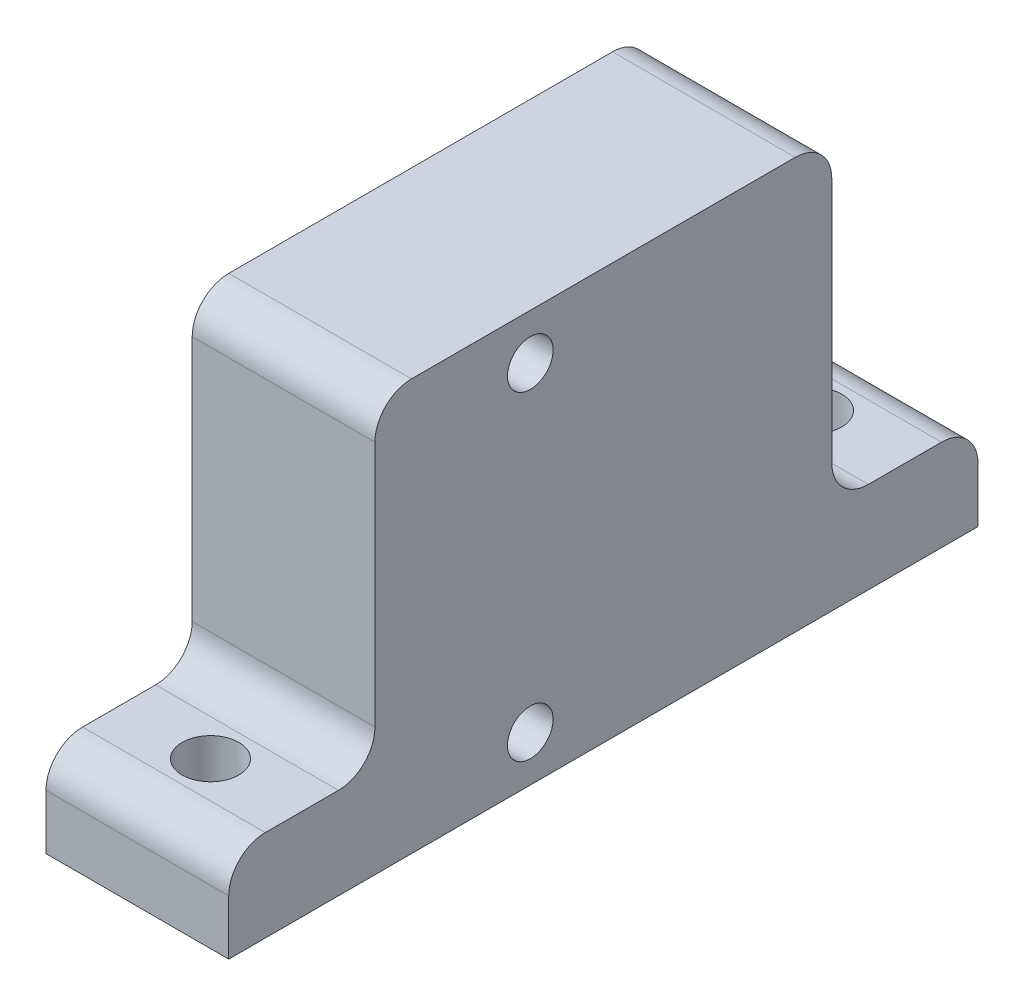
from build123d import *

# Parameters (mm, degrees)
SKETCH1_W           = 25
SKETCH1_H           = 22.5
SKETCH1_R           = 1.25
BOSS_EXTRUDE1_DEPTH = 10
SKETCH4_W           = 10
SKETCH4_H           = 5
BOSS_EXTRUDE3_DEPTH = 8
SKETCH5_W           = 10
SKETCH5_H           = 5
BOSS_EXTRUDE4_DEPTH = 8
FILLET1_R           = 2
CUT_EXTRUDE1_REACH  = 7
SKETCH6_R           = 1.55
CUT_EXTRUDE2_REACH  = 7
SKETCH7_R           = 1.55


with BuildPart() as part:
    # Sketch1 → Boss-Extrude1 (new body)
    with BuildSketch(Plane(origin=(0, 0, 0), x_dir=(0, 0, -1), z_dir=(1, 0, 0))):
        with Locations((4, 0)):
            Rectangle(SKETCH1_W, SKETCH1_H)
        with Locations((0, 8.75)):
            Circle(SKETCH1_R, mode=Mode.SUBTRACT)
        with Locations((0, -8.75)):
            Circle(SKETCH1_R, mode=Mode.SUBTRACT)
    extrude(amount=BOSS_EXTRUDE1_DEPTH)

    # Sketch4 → Boss-Extrude3 (add)
    with BuildSketch(Plane(origin=(0, 0, -16.5), x_dir=(-1, 0, 0), z_dir=(0, 0, -1))):
        with Locations((-5, -8.75)):
            Rectangle(SKETCH4_W, SKETCH4_H)
    extrude(amount=BOSS_EXTRUDE3_DEPTH)

    # Sketch5 → Boss-Extrude4 (add)
    with BuildSketch(Plane.XY.offset(8.5)):
        with Locations((5, -8.75)):
            Rectangle(SKETCH5_W, SKETCH5_H)
    extrude(amount=BOSS_EXTRUDE4_DEPTH)

    # Fillet1
    fillet1_edges = [part.edges().sort_by_distance(p)[0] for p in [
        (5, -6.25, 8.5),
        (5, -6.25, 16.5),
        (5, -6.25, -24.5),
        (5, -6.25, -16.5),
        (5, 11.25, -16.5),
        (5, 11.25, 8.5),
    ]]
    fillet(fillet1_edges, radius=FILLET1_R)

    # Sketch6 → Cut-Extrude1 (cut, up to next)
    with BuildSketch(Plane(origin=(0, -6.25, 0), x_dir=(1, 0, 0), z_dir=(0, 1, 0)), mode=Mode.PRIVATE) as cut_extrude1_sk1:
        with Locations((5, -12.5)):
            Circle(SKETCH6_R)
    cut_extrude1_tool1 = extrude(cut_extrude1_sk1.sketch, amount=-CUT_EXTRUDE1_REACH, mode=Mode.PRIVATE) & part.part
    add(cut_extrude1_tool1.solids().sort_by_distance((5, -6.25, 12.5))[0], mode=Mode.SUBTRACT)

    # Sketch7 → Cut-Extrude2 (cut, up to next)
    with BuildSketch(Plane(origin=(0, -6.25, 0), x_dir=(1, 0, 0), z_dir=(0, 1, 0)), mode=Mode.PRIVATE) as cut_extrude2_sk1:
        with Locations((5, 20.5)):
            Circle(SKETCH7_R)
    cut_extrude2_tool1 = extrude(cut_extrude2_sk1.sketch, amount=-CUT_EXTRUDE2_REACH, mode=Mode.PRIVATE) & part.part
    add(cut_extrude2_tool1.solids().sort_by_distance((5, -6.25, -20.5))[0], mode=Mode.SUBTRACT)


solid = part.part
